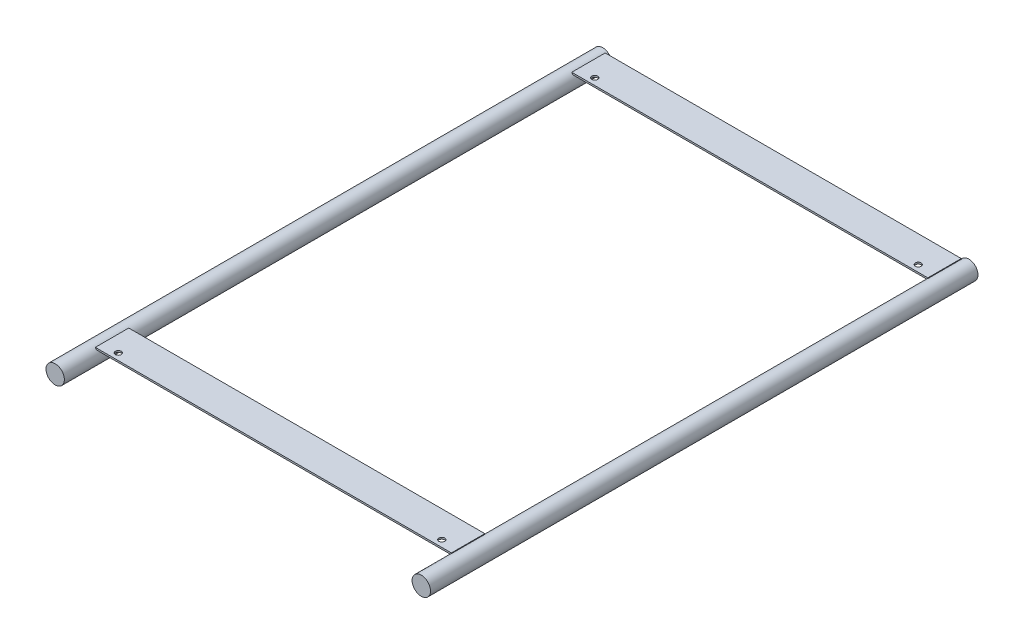
from build123d import *

# Parameters (mm, degrees)
SKETCH1_R             = 11
BOSS_EXTRUDE1_DEPTH   = 655
BOSS_EXTRUDE1_2_DEPTH = 655
SKETCH2_W             = 426
SKETCH2_H             = 40
BOSS_EXTRUDE2_DEPTH   = 2
LPATTERN1_COUNT       = 2
LPATTERN1_PITCH       = 570
SKETCH3_R             = 3.5
CUT_EXTRUDE1_DEPTH    = 695.525737464
SKETCH4_R             = 3.5
CUT_EXTRUDE2_DEPTH    = 695.525737464


with BuildPart() as part:
    # Sketch1 → Boss-Extrude1 (new body)
    with BuildSketch(Plane.XY):
        with Locations((-219, 0)):
            Circle(SKETCH1_R)
    extrude(amount=BOSS_EXTRUDE1_DEPTH)



with BuildPart() as body_2:
    # Sketch1 → Boss-Extrude1 2 (new body)
    with BuildSketch(Plane.XY):
        with Locations((219, 0)):
            Circle(SKETCH1_R)
    extrude(amount=BOSS_EXTRUDE1_2_DEPTH)


with BuildPart() as part_1:
    add(part.part)

    add(body_2.part)  # Boss-Extrude2 merges body 2
    # Sketch2 → Boss-Extrude2 (add)
    with BuildSketch(Plane(origin=(0, 8, 0), x_dir=(1, 0, 0), z_dir=(0, 1, 0))):
        with Locations((0, -23)):
            Rectangle(SKETCH2_W, SKETCH2_H)
    boss_extrude2 = extrude(amount=BOSS_EXTRUDE2_DEPTH)

    # LPattern1: Boss-Extrude2 ×2
    with Locations(*[(0, 0, i * LPATTERN1_PITCH) for i in range(1, LPATTERN1_COUNT)]):
        add(boss_extrude2)

    # Sketch3 → Cut-Extrude1 (cut, through all)
    with BuildSketch(Plane(origin=(0, 10, 0), x_dir=(1, 0, 0), z_dir=(0, 1, 0))):
        with Locations((-193.5, -35)):
            Circle(SKETCH3_R)
        with Locations((193.5, -35)):
            Circle(SKETCH3_R)
    extrude(amount=-CUT_EXTRUDE1_DEPTH, mode=Mode.SUBTRACT)

    # Sketch4 → Cut-Extrude2 (cut, through all)
    with BuildSketch(Plane(origin=(0, 10, 0), x_dir=(1, 0, 0), z_dir=(0, 1, 0))):
        with Locations((-193.5, -605)):
            Circle(SKETCH4_R)
        with Locations((193.5, -605)):
            Circle(SKETCH4_R)
    extrude(amount=-CUT_EXTRUDE2_DEPTH, mode=Mode.SUBTRACT)


solid = part_1.part
